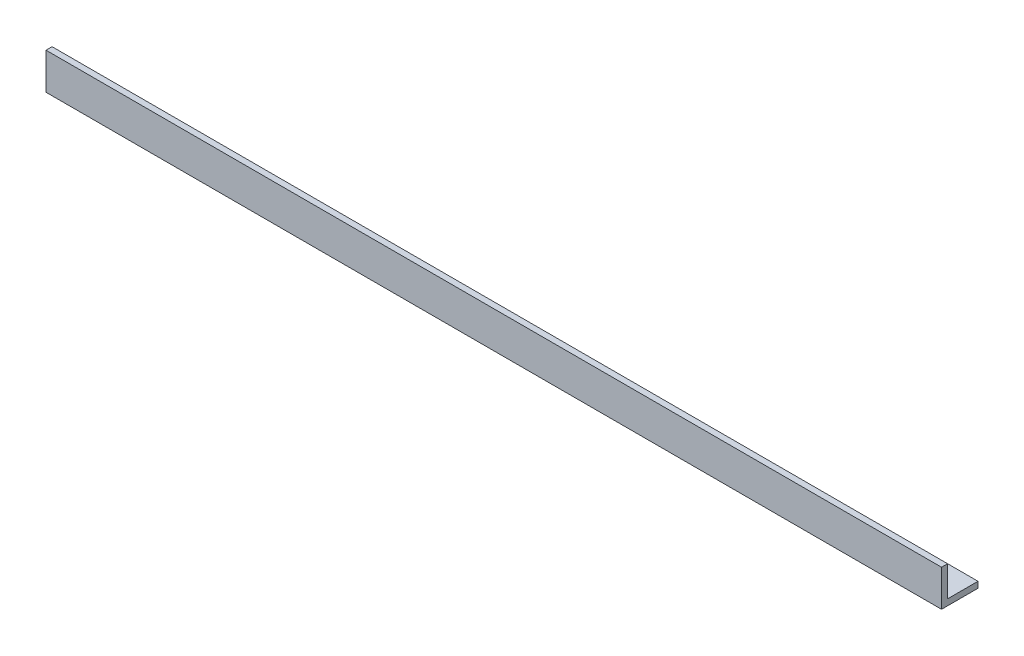
from build123d import *

# Parameters (mm, degrees)
BOSS_EXTRUDE1_DEPTH = 468
SKETCH2_R           = 2.38125
CUT_EXTRUDE1_DEPTH  = 3.175


with BuildPart() as part:
    # Sketch1 → Boss-Extrude1 (new body)
    with BuildSketch(Plane(origin=(0, 0, 0), x_dir=(0, 0, -1), z_dir=(1, 0, 0))):
        Polygon((0, 0), (0, 19.05), (3.175, 19.05), (3.175, 3.175), (19.05, 3.175), (19.05, 0), align=None)
    extrude(amount=-BOSS_EXTRUDE1_DEPTH)

    # Sketch2 → Cut-Extrude1 (cut)
    with BuildSketch(Plane(origin=(0, 3.175, 0), x_dir=(1, 0, 0), z_dir=(0, 1, 0))):
        with Locations((-20.45, 11.273546723)):
            Circle(SKETCH2_R)
        with Locations((-56.2, 11.273546723)):
            Circle(SKETCH2_R)
        with Locations((-91.95, 11.273546723)):
            Circle(SKETCH2_R)
        with Locations((-127.7, 11.273546723)):
            Circle(SKETCH2_R)
        with Locations((-163.45, 11.273546723)):
            Circle(SKETCH2_R)
        with Locations((-199.2, 11.273546723)):
            Circle(SKETCH2_R)
        with Locations((-234.95, 11.273546723)):
            Circle(SKETCH2_R)
        with Locations((-270.7, 11.273546723)):
            Circle(SKETCH2_R)
        with Locations((-306.45, 11.273546723)):
            Circle(SKETCH2_R)
        with Locations((-342.2, 11.273546723)):
            Circle(SKETCH2_R)
        with Locations((-377.95, 11.273546723)):
            Circle(SKETCH2_R)
        with Locations((-413.7, 11.273546723)):
            Circle(SKETCH2_R)
        with Locations((-449.45, 11.273546723)):
            Circle(SKETCH2_R)
    extrude(amount=-CUT_EXTRUDE1_DEPTH, mode=Mode.SUBTRACT)


solid = part.part
